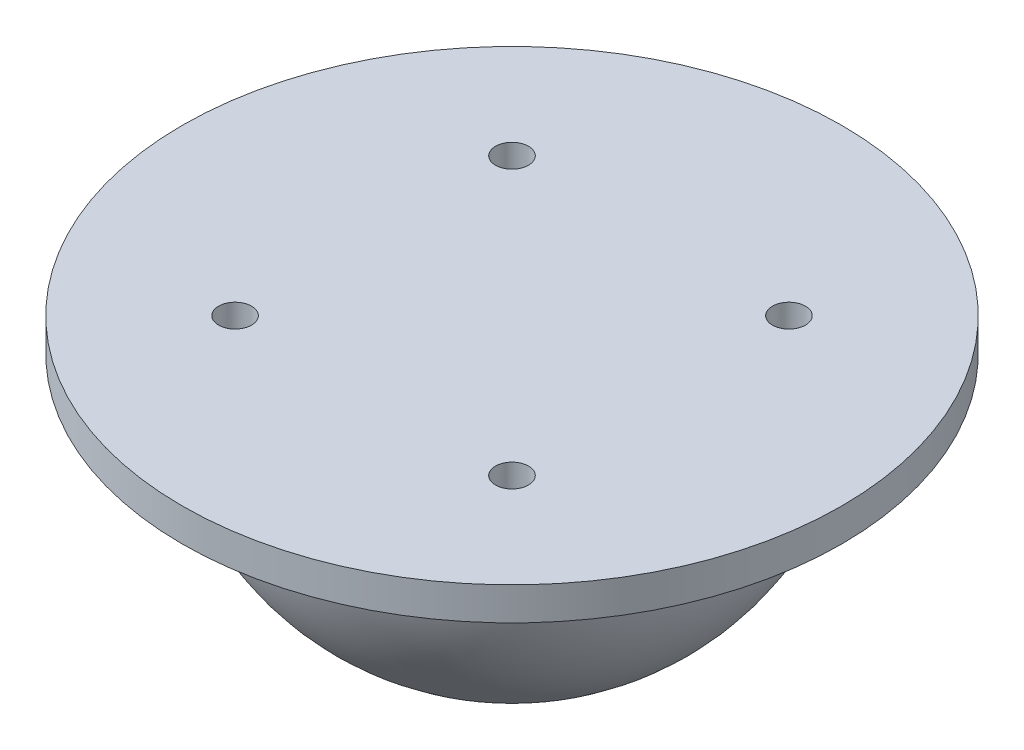
from build123d import *

# Parameters (mm, degrees)
SKETCH_1_R      = 30
SKETCH_1_R_2    = 1.5
EXTRUDE_1_DEPTH = 3


with BuildPart() as part:
    # 草图1 → 凸台-拉伸1 (new body)
    with BuildSketch(Plane(origin=(0, 0, 0), x_dir=(1, 0, 0), z_dir=(0, 1, 0))):
        Circle(SKETCH_1_R)
        with Locations((-12.6, 12.6)):
            Circle(SKETCH_1_R_2, mode=Mode.SUBTRACT)
        with Locations((12.6, 12.6)):
            Circle(SKETCH_1_R_2, mode=Mode.SUBTRACT)
        with Locations((12.6, -12.6)):
            Circle(SKETCH_1_R_2, mode=Mode.SUBTRACT)
        with Locations((-12.6, -12.6)):
            Circle(SKETCH_1_R_2, mode=Mode.SUBTRACT)
    extrude(amount=EXTRUDE_1_DEPTH)

    # 草图3 → 旋转1 (revolve)
    with BuildSketch(Plane(origin=(0, 0, 0), x_dir=(0, 0, -1), z_dir=(1, 0, 0))):
        with BuildLine():
            Line((0, -22.5), (0, 0))
            Line((0, 0), (22.5, 0))
            ThreePointArc((22.5, 0), (15.909902577, -15.909902577), (0, -22.5))
        make_face()
    revolve(axis=Axis((0, 15, 0), (0, 1, 0)))


solid = part.part
